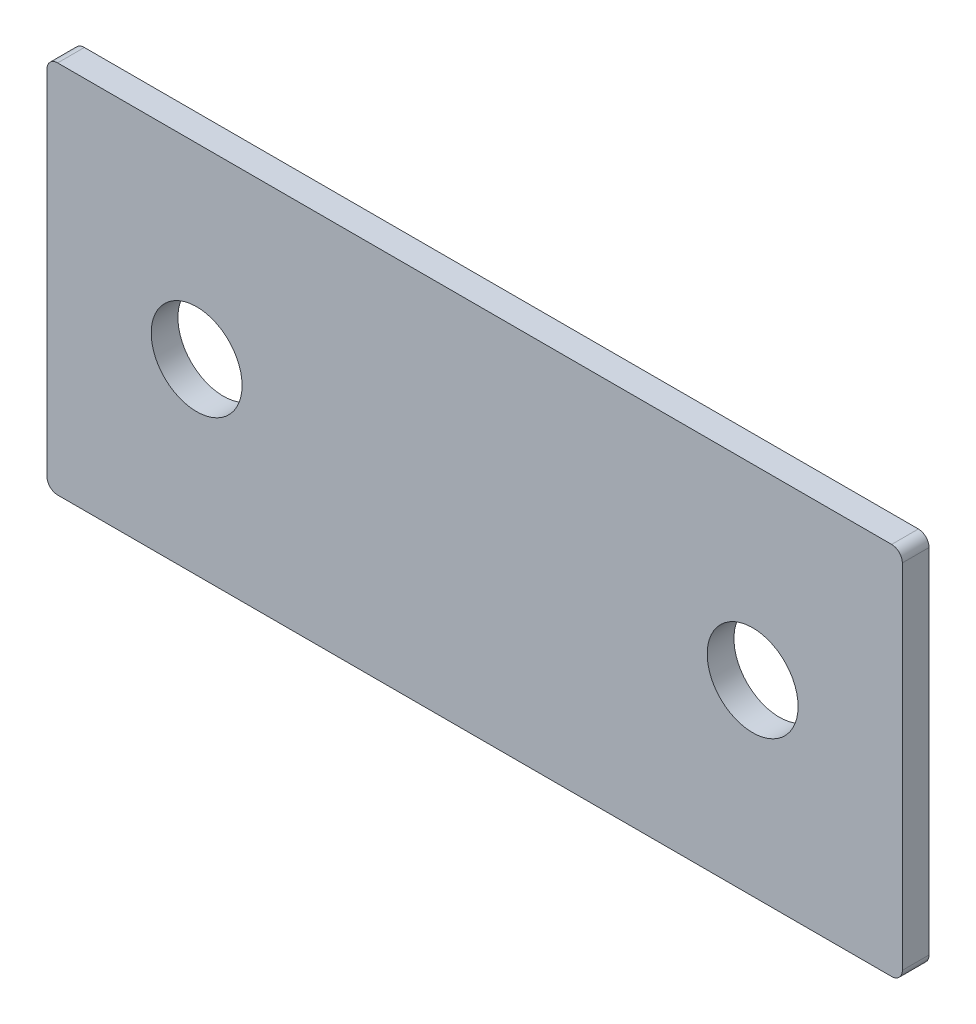
from build123d import *

# Parameters (mm, degrees)
SKETCH_1_W      = 80
SKETCH_1_H      = 35
SKETCH_1_R      = 4.25
EXTRUDE_1_DEPTH = 2.5
FILLET_1_R      = 1


with BuildPart() as part:
    # Эскиз1 → Бобышка-Вытянуть1 (new body)
    with BuildSketch(Plane.XY):
        Rectangle(SKETCH_1_W, SKETCH_1_H)
        with Locations((-26, 0)):
            Circle(SKETCH_1_R, mode=Mode.SUBTRACT)
        with Locations((26, 0)):
            Circle(SKETCH_1_R, mode=Mode.SUBTRACT)
    extrude(amount=EXTRUDE_1_DEPTH)

    # Скругление1
    fillet_1_edges = [part.edges().sort_by_distance(p)[0] for p in [
        (40, -17.5, 1.25),
        (-40, -17.5, 1.25),
        (-40, 17.5, 1.25),
        (40, 17.5, 1.25),
    ]]
    fillet(fillet_1_edges, radius=FILLET_1_R)


solid = part.part
